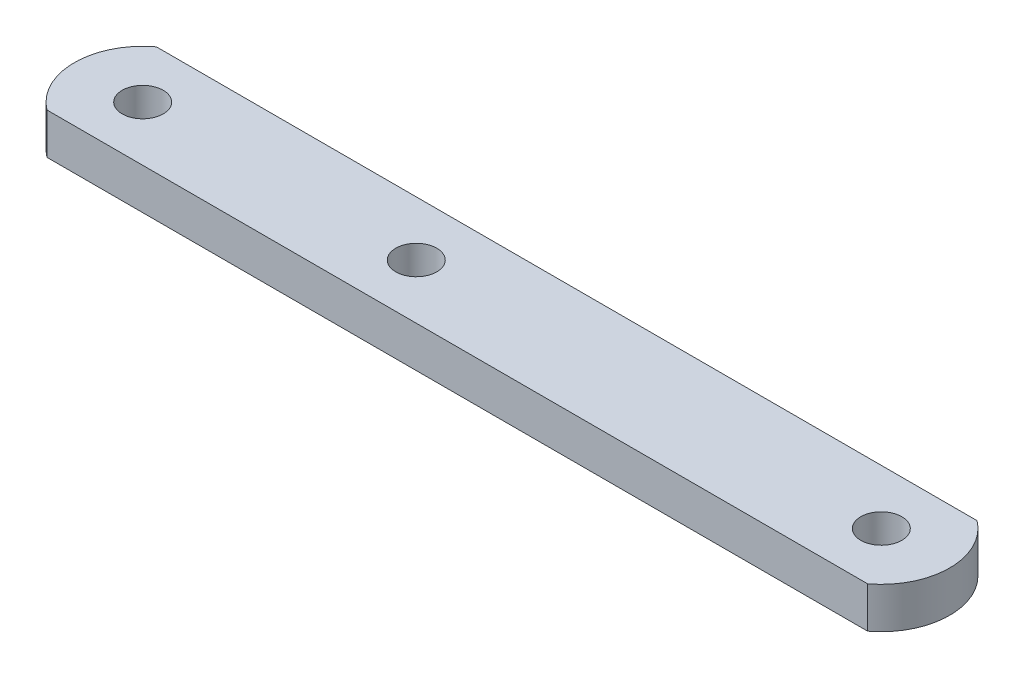
from build123d import *

# Parameters (mm, degrees)
SKETCH1_R           = 1.5
BOSS_EXTRUDE1_DEPTH = 3


with BuildPart() as part:
    # Sketch1 → Boss-Extrude1 (new body)
    with BuildSketch(Plane(origin=(0, 0, 0), x_dir=(1, 0, 0), z_dir=(0, 1, 0))):
        with BuildLine():
            Line((0, 0), (-60, 0))
            ThreePointArc((-60, 0), (-62, 4), (-60, 8))
            Line((-60, 8), (0, 8))
            ThreePointArc((0, 8), (2, 4), (0, 0))
        make_face()
        with Locations((-57, 4)):
            Circle(SKETCH1_R, mode=Mode.SUBTRACT)
        with Locations((-3, 4)):
            Circle(SKETCH1_R, mode=Mode.SUBTRACT)
        with Locations((-37, 4)):
            Circle(SKETCH1_R, mode=Mode.SUBTRACT)
    extrude(amount=BOSS_EXTRUDE1_DEPTH)


solid = part.part
